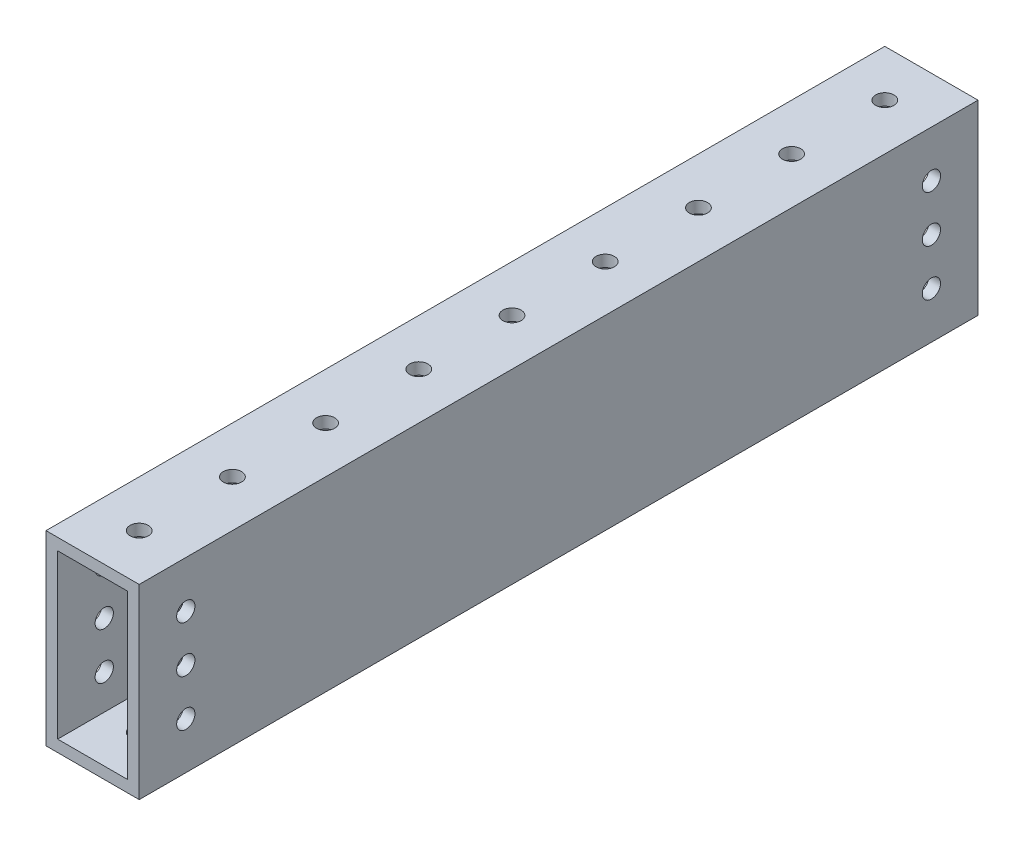
from build123d import *

# Parameters (mm, degrees)
SKETCH1_W           = 25.4
SKETCH1_H           = 50.8
SKETCH1_W_2         = 19.05
SKETCH1_H_2         = 44.45
BOSS_EXTRUDE1_DEPTH = 114.3
SKETCH2_R           = 2.4892
CUT_EXTRUDE1_DEPTH  = 51.8
SKETCH3_R           = 2.4892
CUT_EXTRUDE2_DEPTH  = 26.4


with BuildPart() as part:
    # Sketch1 → Boss-Extrude1 (new body, symmetric)
    with BuildSketch(Plane.XY):
        Rectangle(SKETCH1_W, SKETCH1_H)
        Rectangle(SKETCH1_W_2, SKETCH1_H_2, mode=Mode.SUBTRACT)
    extrude(amount=BOSS_EXTRUDE1_DEPTH, both=True)

    # Sketch2 → Cut-Extrude1 (cut, through all)
    with BuildSketch(Plane(origin=(0, 25.4, 0), x_dir=(1, 0, 0), z_dir=(0, 1, 0))):
        with Locations((0, -101.6)):
            Circle(SKETCH2_R)
        with Locations((0, -76.2)):
            Circle(SKETCH2_R)
        with Locations((0, -50.8)):
            Circle(SKETCH2_R)
        with Locations((0, -25.4)):
            Circle(SKETCH2_R)
        Circle(SKETCH2_R)
        with Locations((0, 25.4)):
            Circle(SKETCH2_R)
        with Locations((0, 50.8)):
            Circle(SKETCH2_R)
        with Locations((0, 76.2)):
            Circle(SKETCH2_R)
        with Locations((0, 101.6)):
            Circle(SKETCH2_R)
    extrude(amount=-CUT_EXTRUDE1_DEPTH, mode=Mode.SUBTRACT)

    # Sketch3 → Cut-Extrude2 (cut, through all)
    with BuildSketch(Plane.ZY.offset(12.7)):
        with Locations((101.6, 0)):
            Circle(SKETCH3_R)
        with Locations((101.6, -12.7)):
            Circle(SKETCH3_R)
        with Locations((101.6, 12.7)):
            Circle(SKETCH3_R)
    cut_extrude2 = extrude(amount=-CUT_EXTRUDE2_DEPTH, mode=Mode.SUBTRACT)

    # Mirror1: Cut-Extrude2 across plane
    add(cut_extrude2.mirror(Plane.XY), mode=Mode.SUBTRACT)


solid = part.part
